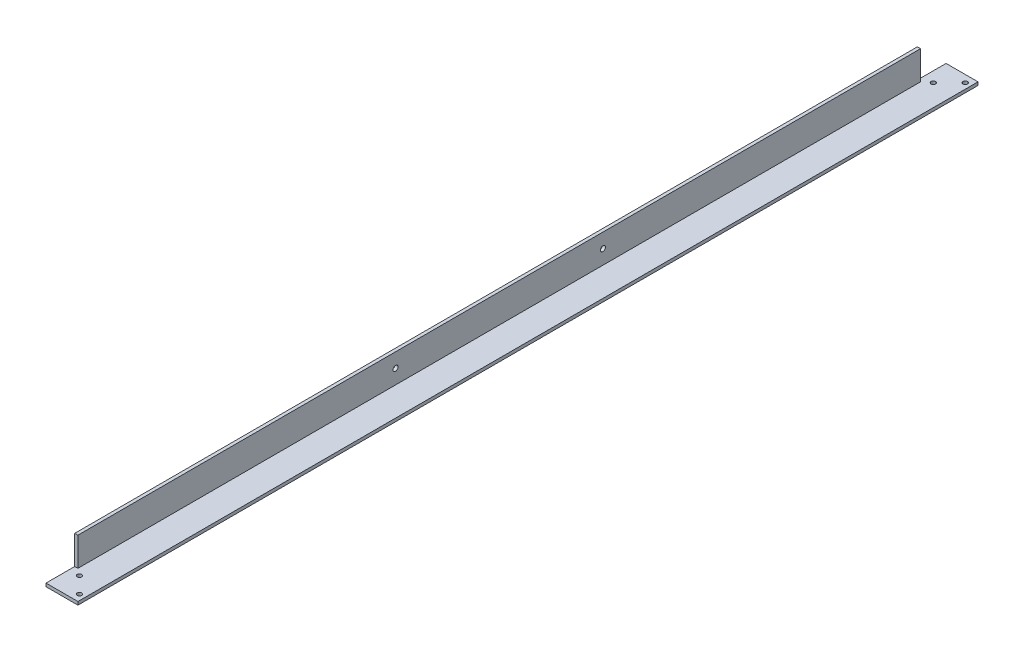
from build123d import *

# Parameters (mm, degrees)
BOSS_EXTRU_1_DEPTH      = 564
ESQUISSE2_W             = 18
ESQUISSE2_H             = 18
ENL_V_MAT_EXTRU_1_DEPTH = 3
ESQUISSE6_R             = 1.4
ENL_V_MAT_EXTRU_5_DEPTH = 3
SKETCH1_R               = 1.6
CUT_EXTRUDE1_DEPTH      = 21


with BuildPart() as part:
    # Esquisse1 → Boss.-Extru.1 (new body)
    with BuildSketch(Plane.XY):
        Polygon((0, 0), (20, 0), (20, 2), (2, 2), (2, 20), (0, 20), align=None)
    extrude(amount=BOSS_EXTRU_1_DEPTH)

    # Esquisse2 → Enlèv. mat.-Extru.1 (cut, through all)
    with BuildSketch(Plane(origin=(2, 0, 0), x_dir=(0, 0, -1), z_dir=(1, 0, 0))):
        with Locations((-555, 11)):
            Rectangle(ESQUISSE2_W, ESQUISSE2_H)
        with Locations((-9, 11)):
            Rectangle(ESQUISSE2_W, ESQUISSE2_H)
    extrude(amount=-ENL_V_MAT_EXTRU_1_DEPTH, mode=Mode.SUBTRACT)

    # Esquisse6 → Enlèv. mat.-Extru.5 (cut, through all)
    with BuildSketch(Plane(origin=(0, 2, 0), x_dir=(1, 0, 0), z_dir=(0, 1, 0))):
        with Locations((6.48, -549.52)):
            Circle(ESQUISSE6_R)
        with Locations((6.48, -14.48)):
            Circle(ESQUISSE6_R)
        with Locations((16.48, -559.52)):
            Circle(ESQUISSE6_R)
        with Locations((16.48, -4.48)):
            Circle(ESQUISSE6_R)
    extrude(amount=-ENL_V_MAT_EXTRU_5_DEPTH, mode=Mode.SUBTRACT)

    # Sketch1 → Cut-Extrude1 (cut, through all)
    with BuildSketch(Plane.ZY):
        with Locations((217, 11)):
            Circle(SKETCH1_R)
        with Locations((347, 11)):
            Circle(SKETCH1_R)
    extrude(amount=-CUT_EXTRUDE1_DEPTH, mode=Mode.SUBTRACT)


solid = part.part
